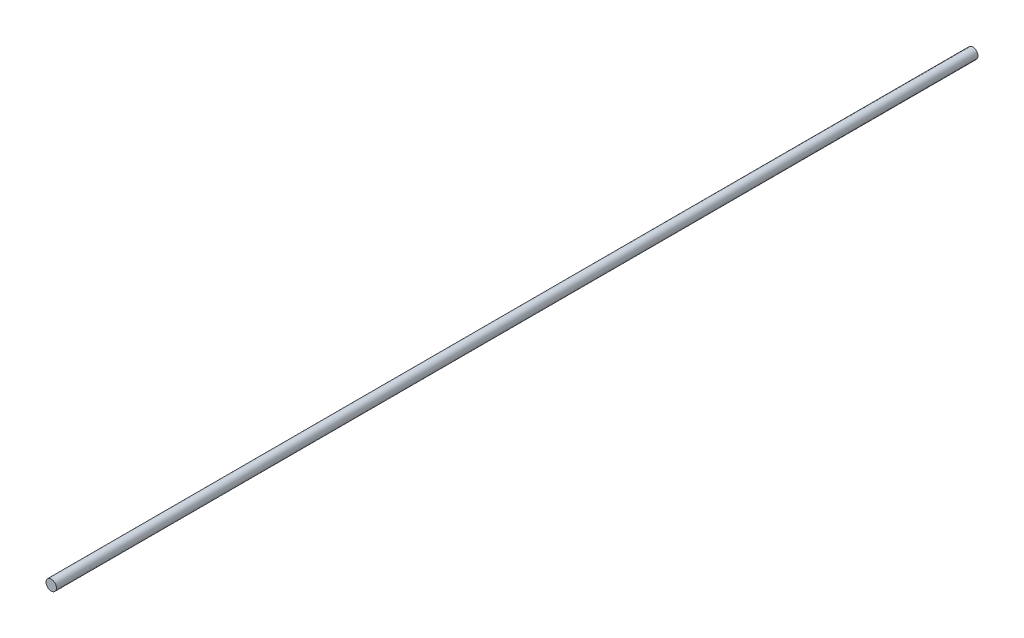
from build123d import *

# Parameters (mm, degrees)
ESBO_O1_W = 13
ESBO_O1_H = 2300


with BuildPart() as part:
    # Esboço1 → Revolução1 (revolve)
    with BuildSketch(Plane.XZ):
        with Locations((6.5, 1150)):
            Rectangle(ESBO_O1_W, ESBO_O1_H)
    revolve(axis=Axis((0, 0, 2300), (0, 0, -1)))


solid = part.part
